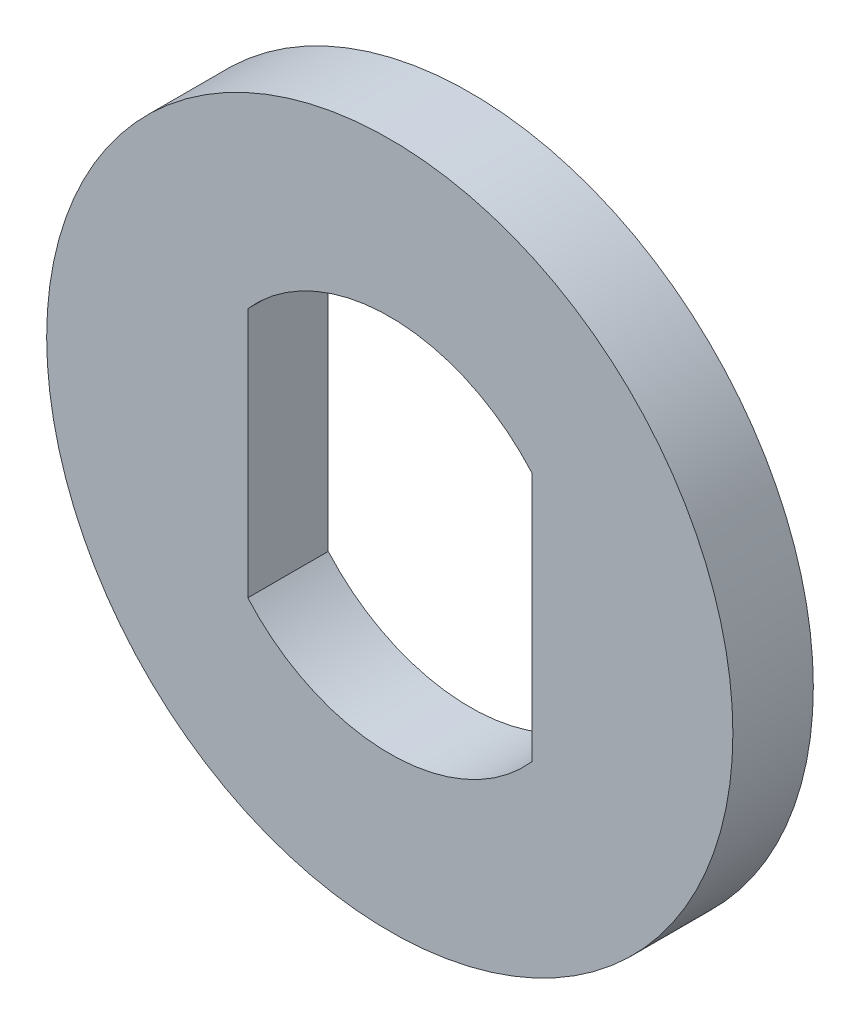
from build123d import *

# Parameters (mm, degrees)
ESQUISSE1_R      = 7.25
EXTRUSION1_DEPTH = 0.85


with BuildPart() as part:
    # Esquisse1 → Extrusion1 (new body, symmetric)
    with BuildSketch(Plane.XY):
        Circle(ESQUISSE1_R)
        with BuildLine():
            Line((-3, 2.645751311), (-3, -2.645751311))
            ThreePointArc((-3, -2.645751311), (0, -4), (3, -2.645751311))
            Line((3, -2.645751311), (3, 2.645751311))
            ThreePointArc((3, 2.645751311), (0, 4), (-3, 2.645751311))
        make_face(mode=Mode.SUBTRACT)
    extrude(amount=EXTRUSION1_DEPTH, both=True)


solid = part.part
